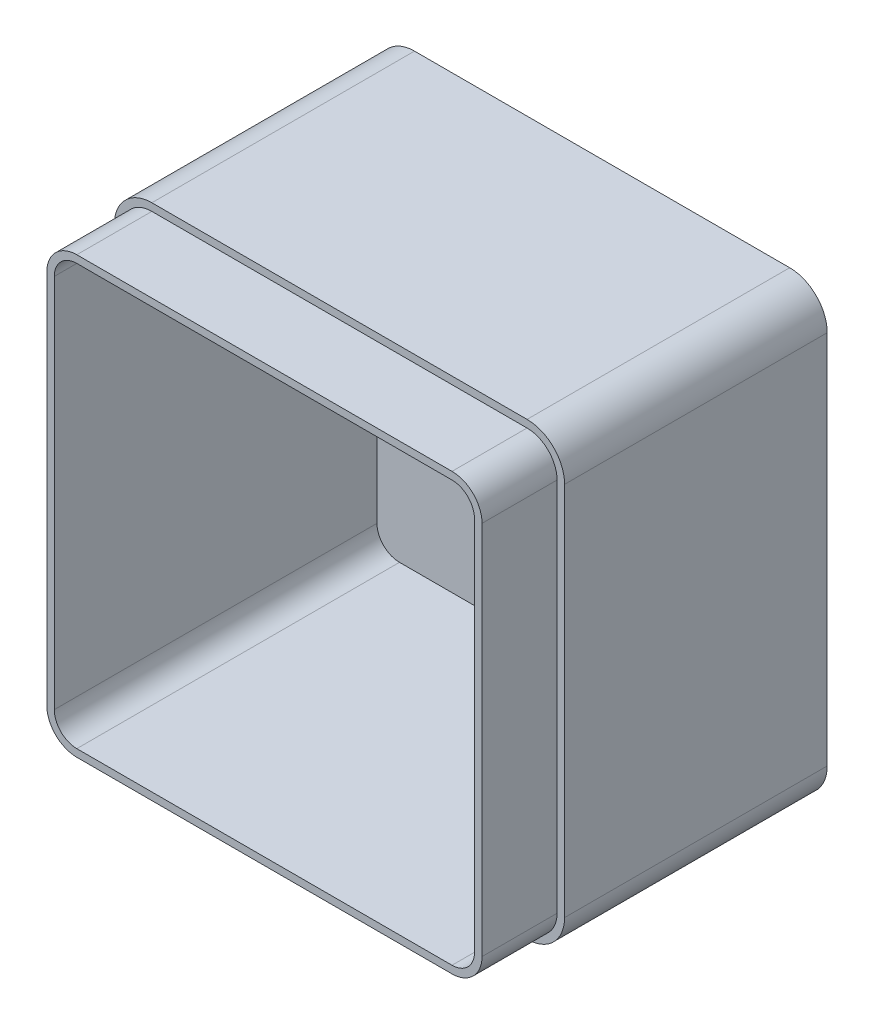
from build123d import *

# Parameters (mm, degrees)
SKETCH1_W           = 120
SKETCH1_H           = 120
BOSS_EXTRUDE2_DEPTH = 90
FILLET1_R           = 10
SHELL1_T            = -4
SKETCH2_OUTSIDE_W   = 160.418
SKETCH2_OUTSIDE_H   = 160.418
CUT_EXTRUDE1_DEPTH  = 20


with BuildPart() as part:
    # Sketch1 → Boss-Extrude2 (new body)
    with BuildSketch(Plane.XY):
        with Locations((60, 60)):
            Rectangle(SKETCH1_W, SKETCH1_H)
    extrude(amount=BOSS_EXTRUDE2_DEPTH)

    # Fillet1
    fillet1_edges = [part.edges().sort_by_distance(p)[0] for p in [
        (0, 120, 45),
        (120, 120, 45),
        (120, 0, 45),
        (0, 0, 45),
    ]]
    fillet(fillet1_edges, radius=FILLET1_R)

    # Shell1
    shell1_openings = [part.faces().sort_by_distance(p)[0] for p in [
        (60, 60, 90),
    ]]
    offset(amount=SHELL1_T, openings=shell1_openings, kind=Kind.INTERSECTION)

    # Sketch2 outside → Cut-Extrude1 (cut)
    with BuildSketch(Plane.XY.offset(90)):
        with Locations((60, 60)):
            Rectangle(SKETCH2_OUTSIDE_W, SKETCH2_OUTSIDE_H)
        with BuildLine():
            Line((10, 2), (110, 2))
            ThreePointArc((110, 2), (115.656854249, 4.343145751), (118, 10))
            Line((118, 10), (118, 110))
            ThreePointArc((118, 110), (115.656854249, 115.656854249), (110, 118))
            Line((110, 118), (10, 118))
            ThreePointArc((10, 118), (4.343145751, 115.656854249), (2, 110))
            Line((2, 110), (2, 10))
            ThreePointArc((2, 10), (4.343145751, 4.343145751), (10, 2))
        make_face(mode=Mode.SUBTRACT)
    extrude(amount=-CUT_EXTRUDE1_DEPTH, mode=Mode.SUBTRACT)


solid = part.part
